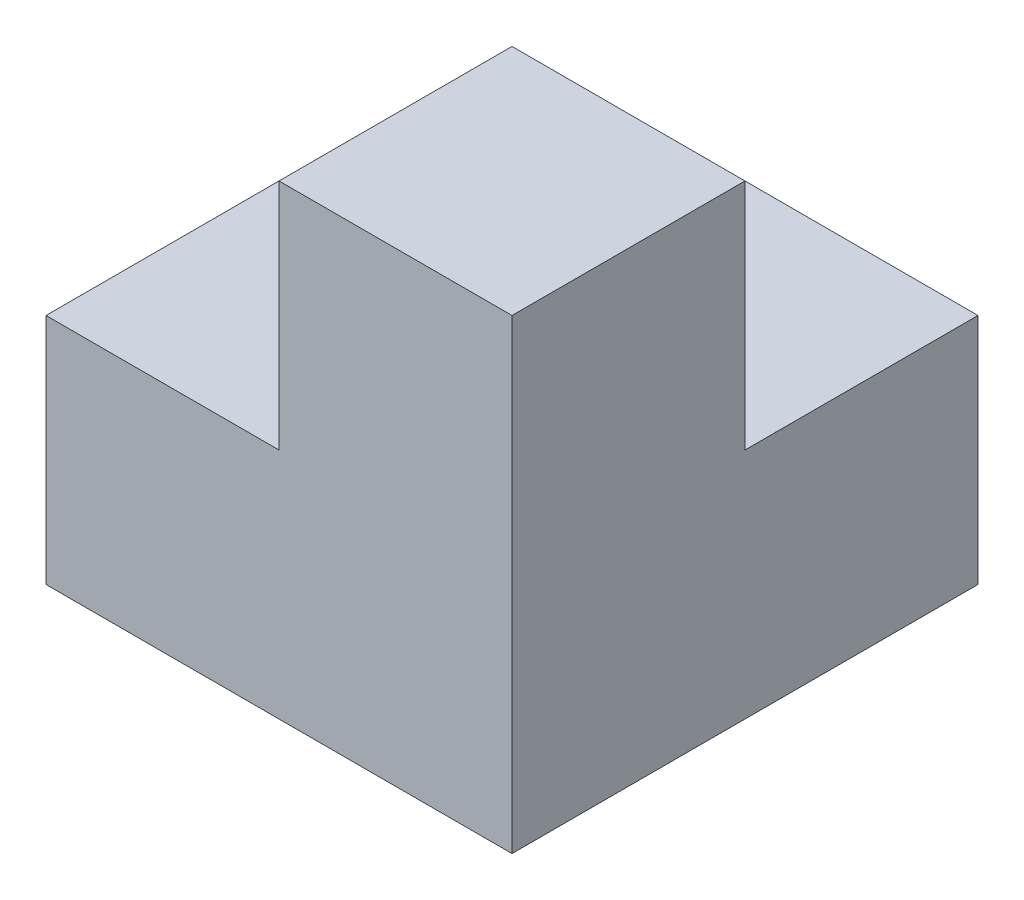
from build123d import *

# Parameters (mm, degrees)
SKETCH1_W           = 4
SKETCH1_H           = 4
BOSS_EXTRUDE1_DEPTH = 4
CUT_EXTRUDE1_DEPTH  = 2


with BuildPart() as part:
    # Sketch1 → Boss-Extrude1 (new body)
    with BuildSketch(Plane(origin=(0, 0, 0), x_dir=(1, 0, 0), z_dir=(0, 1, 0))):
        with Locations((2, 2)):
            Rectangle(SKETCH1_W, SKETCH1_H)
    extrude(amount=BOSS_EXTRUDE1_DEPTH)

    # Sketch2 → Cut-Extrude1 (cut)
    with BuildSketch(Plane(origin=(0, 4, 0), x_dir=(1, 0, 0), z_dir=(0, 1, 0))):
        Polygon((2, 0), (2, 2), (4, 2), (4, 4), (0, 4), (0, 0), align=None)
    extrude(amount=-CUT_EXTRUDE1_DEPTH, mode=Mode.SUBTRACT)


solid = part.part
